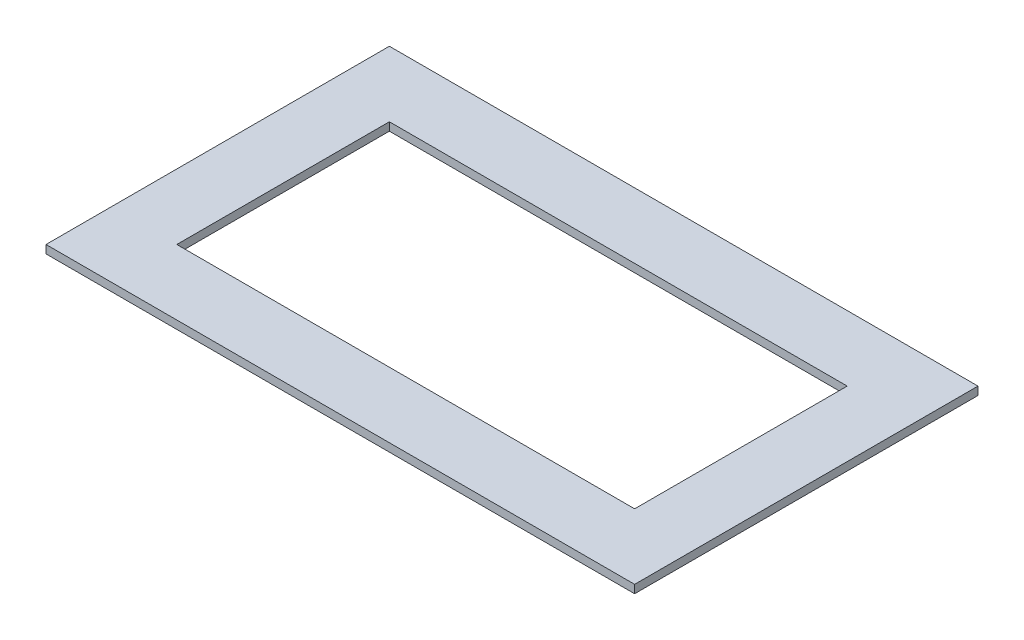
from build123d import *

# Parameters (mm, degrees)
SKETCH1_W           = 360
SKETCH1_H           = 210
SKETCH1_W_2         = 280
SKETCH1_H_2         = 130
BOSS_EXTRUDE1_DEPTH = 5


with BuildPart() as part:
    # Sketch1 → Boss-Extrude1 (new body)
    with BuildSketch(Plane(origin=(0, 0, 0), x_dir=(1, 0, 0), z_dir=(0, 1, 0))):
        Rectangle(SKETCH1_W, SKETCH1_H)
        Rectangle(SKETCH1_W_2, SKETCH1_H_2, mode=Mode.SUBTRACT)
    extrude(amount=BOSS_EXTRUDE1_DEPTH)


solid = part.part
